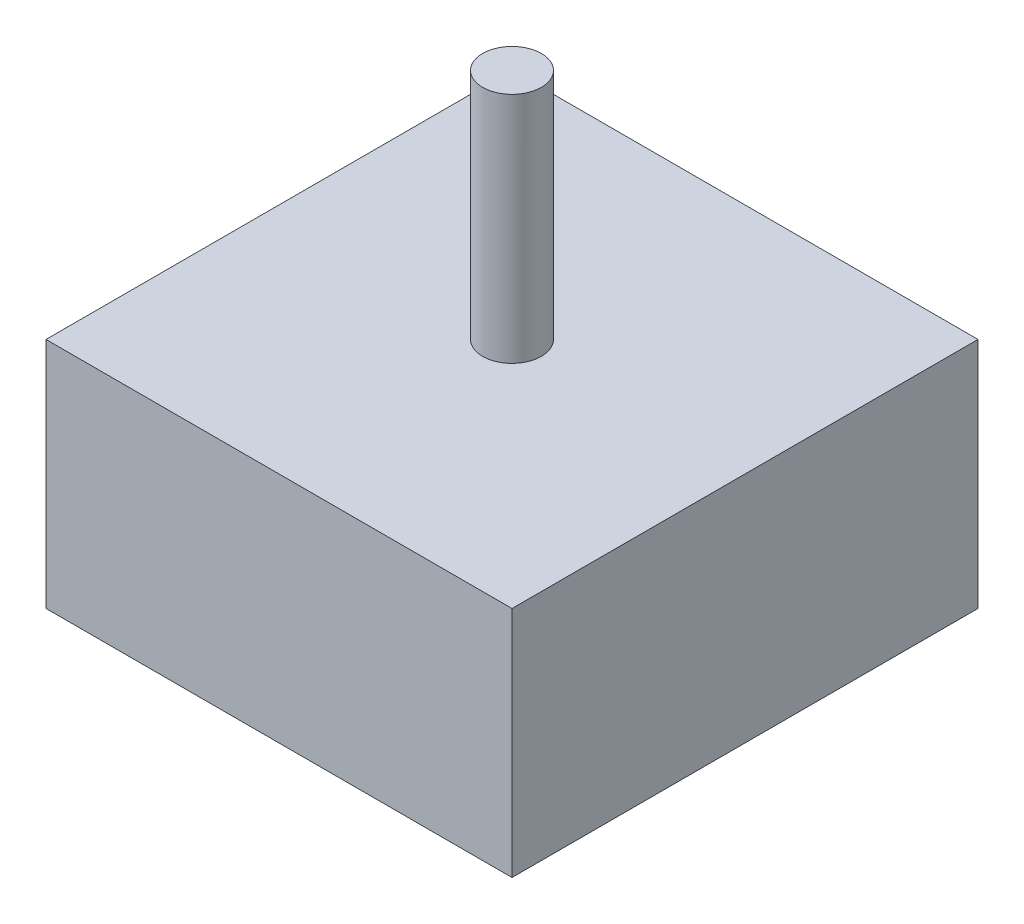
from build123d import *

# Parameters (mm, degrees)
SKETCH1_W           = 50
SKETCH1_H           = 50
BOSS_EXTRUDE1_DEPTH = 25
SKETCH2_R           = 3.15
BOSS_EXTRUDE2_DEPTH = 25
SKETCH3_W           = 5
SKETCH3_H           = 5
CUT_EXTRUDE2_DEPTH  = 6


with BuildPart() as part:
    # Sketch1 → Boss-Extrude1 (new body)
    with BuildSketch(Plane(origin=(0, 0, 0), x_dir=(1, 0, 0), z_dir=(0, 1, 0))):
        Rectangle(SKETCH1_W, SKETCH1_H)
    extrude(amount=BOSS_EXTRUDE1_DEPTH)

    # Sketch2 → Boss-Extrude2 (add)
    with BuildSketch(Plane(origin=(0, 25, 0), x_dir=(1, 0, 0), z_dir=(0, 1, 0))):
        Circle(SKETCH2_R)
    extrude(amount=BOSS_EXTRUDE2_DEPTH)

    # Sketch3 → Cut-Extrude2 (cut)
    with BuildSketch(Plane.ZY.offset(25)):
        with Locations((0, 12.5)):
            Rectangle(SKETCH3_W, SKETCH3_H)
    extrude(amount=-CUT_EXTRUDE2_DEPTH, mode=Mode.SUBTRACT)


solid = part.part
